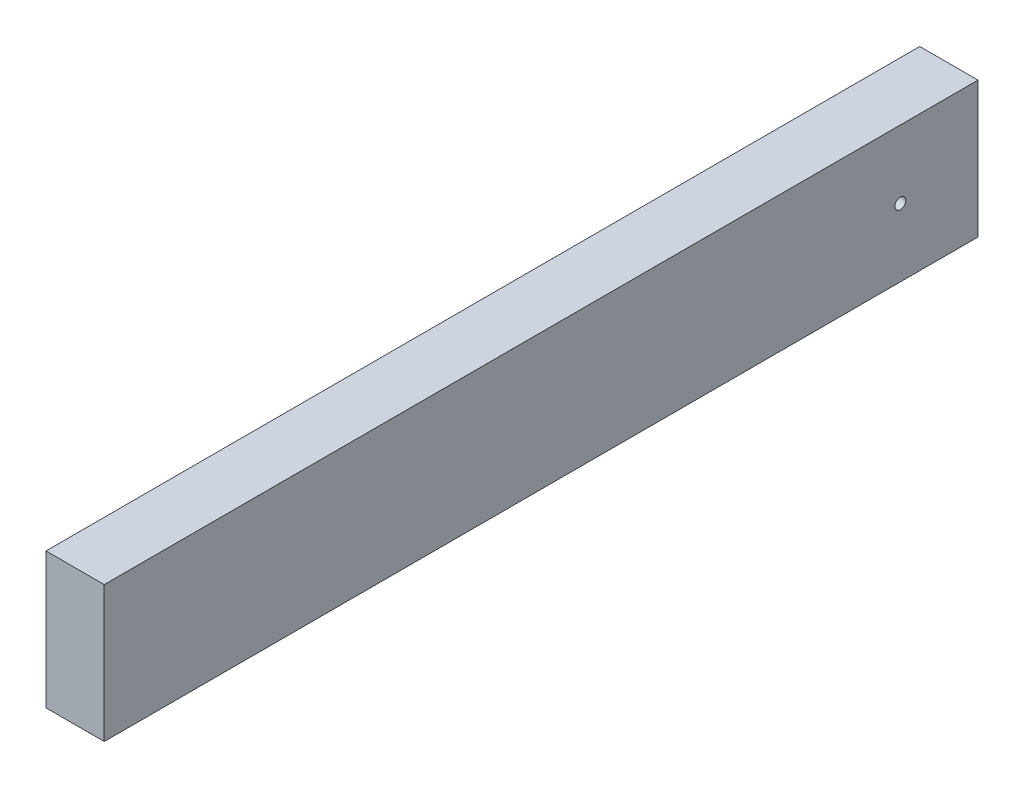
from build123d import *

# Parameters (mm, degrees)
SKETCH1_W                       = 38.1
SKETCH1_H                       = 88.9
BOSS_EXTRUDE1_DEPTH             = 571.5
F_9_32_0_28125_DIAMETER_HOLE1_D = 7.14375


with BuildPart() as part:
    # Sketch1 → Boss-Extrude1 (new body)
    with BuildSketch(Plane.XY):
        Rectangle(SKETCH1_W, SKETCH1_H)
    extrude(amount=BOSS_EXTRUDE1_DEPTH)

    # 9/32 (0.28125) Diameter Hole1 (through all)
    with Locations(Plane(origin=(19.05, 0, 0), x_dir=(0, 0, -1), z_dir=(1, 0, 0))):
        with Locations((-50.8, 0)):
            Hole(F_9_32_0_28125_DIAMETER_HOLE1_D / 2)


solid = part.part
